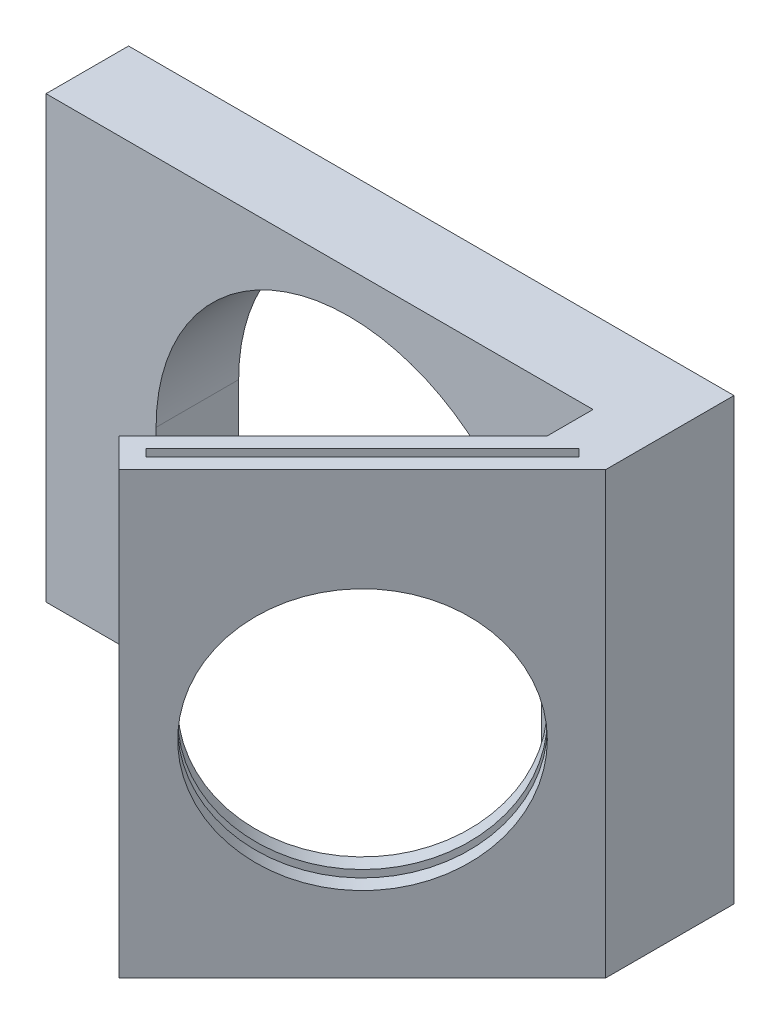
from build123d import *

# Parameters (mm, degrees)
SALIENTE_EXTRUIR1_DEPTH = 6
SALIENTE_EXTRUIR2_DEPTH = 32
CORTAR_EXTRUIR1_REACH   = 39.705
CROQUIS3_R              = 9.5
CORTAR_EXTRUIR2_DEPTH   = 31


with BuildPart() as part:
    # Croquis1 → Saliente-Extruir1 (new body)
    with BuildSketch(Plane.XY):
        with BuildLine():
            Line((-22, 17), (-22, -15))
            Line((-22, -15), (-14, -15))
            Line((-14, -15), (-14, 0))
            ThreePointArc((-14, 0), (0, 14), (14, 0))
            Line((14, 0), (14, -15))
            Line((14, -15), (22, -15))
            Line((22, -15), (22, 17))
            Line((22, 17), (-22, 17))
        make_face()
    extrude(amount=SALIENTE_EXTRUIR1_DEPTH)

    # Croquis2 → Saliente-Extruir2 (add)
    with BuildSketch(Plane.XZ.offset(15)):
        Polygon((22, 6), (22, 9.32233047), (4.32233047, 27), (2.201010127, 24.878679656), (17.757359313, 9.32233047), (17.757359313, 6), align=None)
    extrude(amount=-SALIENTE_EXTRUIR2_DEPTH)

    # Croquis3 → Cortar-Extruir1 (cut, up to next)
    with BuildSketch(Plane(origin=(15.661165235, 0, 15.661165235), x_dir=(0.707106781, 0, -0.707106781), z_dir=(0.707106781, 0, 0.707106781)), mode=Mode.PRIVATE) as cortar_extruir1_sk1:
        with Locations((-3.535533906, 0)):
            Circle(CROQUIS3_R)
    cortar_extruir1_tool1 = extrude(cortar_extruir1_sk1.sketch, amount=-CORTAR_EXTRUIR1_REACH, mode=Mode.PRIVATE) & part.part
    add(cortar_extruir1_tool1.solids().sort_by_distance((13.161165, 0, 18.161165))[0], mode=Mode.SUBTRACT)

    # Croquis5 → Cortar-Extruir2 (cut)
    with BuildSketch(Plane(origin=(0, 17, 0), x_dir=(1, 0, 0), z_dir=(0, 1, 0))):
        Polygon((4.499107166, -25.232233047), (20.232233047, -9.499107166), (19.701902961, -8.96877708), (3.96877708, -24.701902961), align=None)
    extrude(amount=-CORTAR_EXTRUIR2_DEPTH, mode=Mode.SUBTRACT)


solid = part.part
